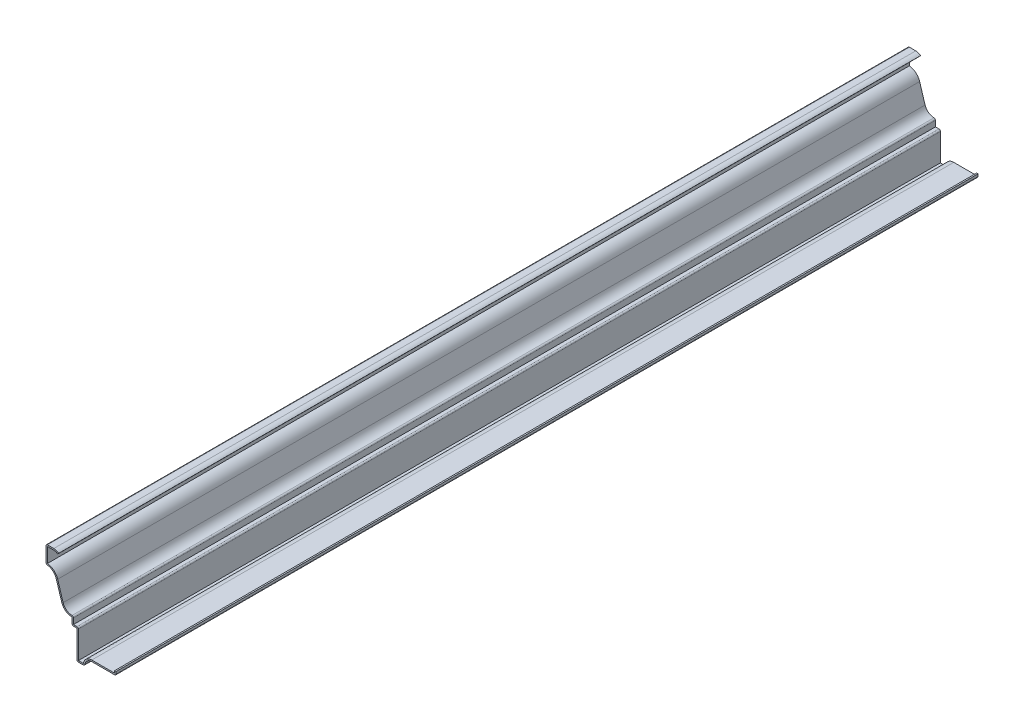
from build123d import *

# Parameters (mm, degrees)
EXTRUDE_THIN1_DEPTH = 762
FILLET1_R           = 1.27


with BuildPart() as part:
    # Sketch1 → Extrude-Thin1 (new body)
    with BuildSketch(Plane.XY):
        with BuildLine():
            Line((0, 0), (0, -3.175))
            Line((0, -3.175), (-21.43125, -3.175))
            ThreePointArc((-21.43125, -3.175), (-25.921378, -5.034872), (-27.78125, -9.525))
            Line((-27.78125, -9.525), (-34.528125, -9.525))
            Line((-34.528125, -9.525), (-34.528125, 15.875))
            Line((-34.528125, 15.875), (-38.89375, 15.875))
            Line((-38.89375, 15.875), (-38.89375, 22.225))
            ThreePointArc((-38.89375, 22.225), (-44.544809, 24.082461), (-47.991853, 28.9304))
            Line((-47.991853, 28.9304), (-52.814397, 44.491475))
            ThreePointArc((-52.814397, 44.491475), (-56.261441, 49.339414), (-61.9125, 51.196875))
            Line((-61.9125, 51.196875), (-61.9125, 66.675))
            Line((-61.9125, 66.675), (-55.00013, 66.675))
            ThreePointArc((-55.00013, 66.675), (-52.755066, 66.264881), (-50.8, 65.0875))
            Line((-50.8, 65.0875), (-51.640026, 64.135))
            ThreePointArc((-51.640026, 64.135), (-53.204079, 65.076905), (-55.00013, 65.405))
            Line((-55.00013, 65.405), (-60.6425, 65.405))
            Line((-60.6425, 65.405), (-60.6425, 52.391909))
            ThreePointArc((-60.6425, 52.391909), (-55.007036, 49.96926), (-51.601316, 44.867421))
            Line((-51.601316, 44.867421), (-46.778773, 29.306347))
            ThreePointArc((-46.778773, 29.306347), (-43.264039, 24.746743), (-37.62375, 23.593277))
            Line((-37.62375, 23.593277), (-37.62375, 17.145))
            Line((-37.62375, 17.145), (-33.258125, 17.145))
            Line((-33.258125, 17.145), (-33.258125, -8.255))
            Line((-33.258125, -8.255), (-28.944671, -8.255))
            ThreePointArc((-28.944671, -8.255), (-26.349939, -3.705129), (-21.43125, -1.905))
            Line((-21.43125, -1.905), (-1.27, -1.905))
            Line((-1.27, -1.905), (-1.27, 0))
            Line((-1.27, 0), (0, 0))
        make_face()
    extrude(amount=-EXTRUDE_THIN1_DEPTH)

    # Fillet1
    fillet1_edges = [part.edges().sort_by_distance(p)[0] for p in [
        (-37.62375, 23.593277, -381),
        (-33.258125, 17.145, -381),
        (0, -3.175, -381),
        (-27.78125, -9.525, -381),
        (-34.528125, -9.525, -381),
        (-38.89375, 15.875, -381),
        (-61.9125, 51.196875, -381),
        (-61.9125, 66.675, -381),
    ]]
    fillet(fillet1_edges, radius=FILLET1_R)


solid = part.part
